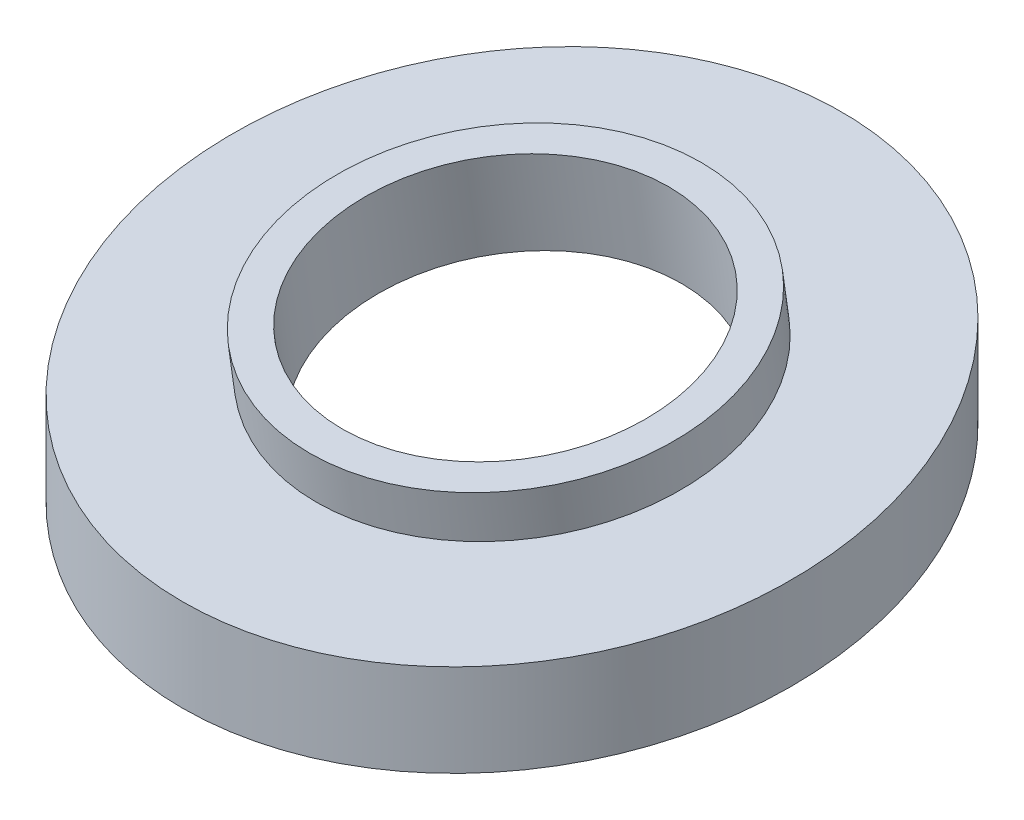
from build123d import *

# Parameters (mm, degrees)
SKETCH_1_R          = 25
EXTRUDE_1_DEPTH     = 30
CUT_EXTRUDE_1_DEPTH = 31.5
SKETCH_10_R         = 15
EXTRUDE_2_DEPTH     = 3.5
SKETCH_11_R         = 21
CUT_EXTRUDE_8_DEPTH = 3.5
SKETCH_12_R         = 12.5
CUT_EXTRUDE_9_DEPTH = 23.5


with BuildPart() as part:
    # 草图1 → 凸台-拉伸1 (new body)
    with BuildSketch(Plane(origin=(0, 0, 0), x_dir=(1, 0, 0), z_dir=(0, 1, 0))):
        Circle(SKETCH_1_R)
    extrude(amount=EXTRUDE_1_DEPTH)

    # 草图3 → 切除-拉伸1 (cut, symmetric)
    with BuildSketch(Plane(origin=(0, 0, 0), x_dir=(0, 0, -1), z_dir=(1, 0, 0))):
        Polygon((-25, 7), (25, 14.188898505), (25, 39.510034579), (-25, 39.510034579), align=None)
        Polygon((-25, 0), (25, 7.188898505), (25, -11.572478834), (-25, -11.572478834), align=None)
    extrude(amount=CUT_EXTRUDE_1_DEPTH, both=True, mode=Mode.SUBTRACT)

    # 草图10 → 凸台-拉伸2 (add)
    with BuildSketch(Plane(origin=(0, 10.379875382, 1.492397412), x_dir=(1, 0, 0), z_dir=(0, 0.989821487, 0.142314524))):
        with Locations((0, 1.507744004)):
            Circle(SKETCH_10_R)
    extrude(amount=EXTRUDE_2_DEPTH)

    # 草图11 → 切除-拉伸8 (cut)
    with BuildSketch(Plane(origin=(0, 3.521649349, 0.506335595), x_dir=(1, 0, 0), z_dir=(0, -0.989821487, -0.142314524))):
        with Locations((0, -1.507744004)):
            Circle(SKETCH_11_R)
    extrude(amount=-CUT_EXTRUDE_8_DEPTH, mode=Mode.SUBTRACT)

    # 草图12 → 切除-拉伸9 (cut)
    with BuildSketch(Plane(origin=(0, 13.844250587, 1.990498247), x_dir=(1, 0, 0), z_dir=(0, 0.989821487, 0.142314524))):
        with Locations((0, 1.507744004)):
            Circle(SKETCH_12_R)
    extrude(amount=-CUT_EXTRUDE_9_DEPTH, mode=Mode.SUBTRACT)


solid = part.part
